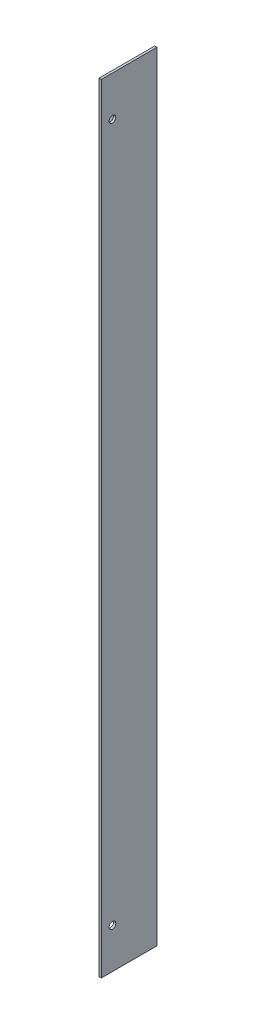
from build123d import *

# Parameters (mm, degrees)
CROQUIS2_W              = 1
CROQUIS2_H              = 350
SALIENTE_EXTRUIR2_DEPTH = 25
CROQUIS5_R              = 1.5
CORTAR_EXTRUIR2_DEPTH   = 1
CROQUIS1_R              = 1.5
SALIENTE_EXTRUIR3_DEPTH = 1


with BuildPart() as part:
    # Croquis2 → Saliente-Extruir2 (new body)
    with BuildSketch(Plane.XY):
        with Locations((-54.941785307, -113.819624774)):
            Rectangle(CROQUIS2_W, CROQUIS2_H)
    extrude(amount=SALIENTE_EXTRUIR2_DEPTH)

    # Croquis5 → Cortar-Extruir2 (cut)
    with BuildSketch(Plane(origin=(-54.441785307, 0, 0), x_dir=(0, 0, -1), z_dir=(1, 0, 0))):
        with Locations((-20, 43.180375226)):
            Circle(CROQUIS5_R)
        with Locations((-20, -270.819624774)):
            Circle(CROQUIS5_R)
    extrude(amount=-CORTAR_EXTRUIR2_DEPTH, mode=Mode.SUBTRACT)

    # Croquis1 → Saliente-Extruir3 (add)
    with BuildSketch(Plane.XY):
        Polygon((-55.441785307, 61.180375226), (-79.441785307, 37.180375226), (-79.441785307, -264.819624774), (-55.441785307, -288.819624774), align=None)
        with Locations((-74.441785307, 21.180375226)):
            Circle(CROQUIS1_R, mode=Mode.SUBTRACT)
        with Locations((-74.441785307, -248.819624774)):
            Circle(CROQUIS1_R, mode=Mode.SUBTRACT)
        with Locations((-74.441785307, -168.819624774)):
            Circle(CROQUIS1_R, mode=Mode.SUBTRACT)
    extrude(amount=SALIENTE_EXTRUIR3_DEPTH)


solid = part.part
